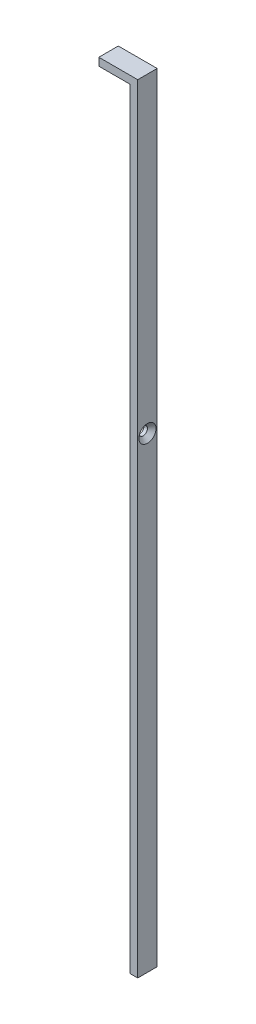
from build123d import *

# Parameters (mm, degrees)
BOSS_EXTRUDE1_DEPTH = 5


with BuildPart() as part:
    # Sketch1 → Boss-Extrude1 (new body)
    with BuildSketch(Plane.XY):
        Polygon((-8, 0), (0, 0), (0, -198), (2, -198), (2, 2), (-8, 2), align=None)
    extrude(amount=BOSS_EXTRUDE1_DEPTH)

    # Sketch3 → CSK for M2 Flat Head Machine Screw1 (revolve, cut)
    with BuildSketch(Plane(origin=(2, -78, 2.5), x_dir=(0, 0, -1), z_dir=(0, 1, 0))):
        Polygon((0, 0), (0, 2), (1.1, 2), (1.1, 1.1), (2.2, 0), align=None)
    revolve(axis=Axis((8.35, -78, 2.5), (-1, 0, 0)), mode=Mode.SUBTRACT)


solid = part.part
